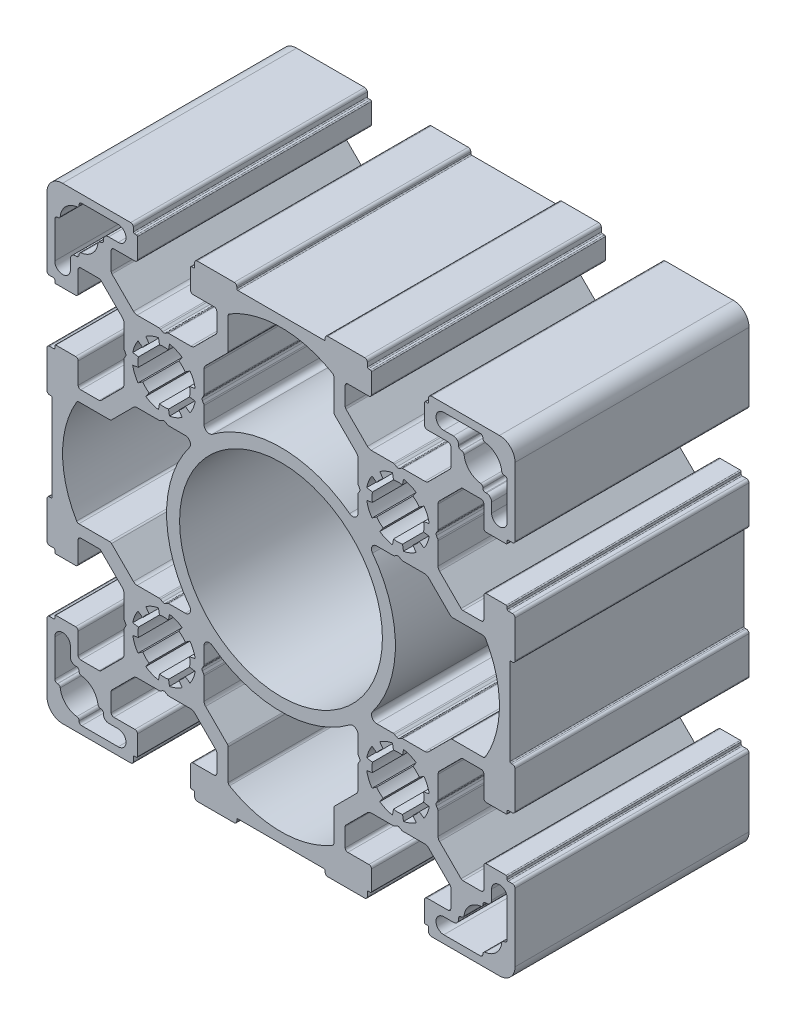
from build123d import *

# Parameters (mm, degrees)
SKETCH_1_R      = 19.5
EXTRUDE_1_DEPTH = 45


with BuildPart() as part:
    # Эскиз1 → Бобышка-Вытянуть1 (new body)
    with BuildSketch(Plane.XY):
        with BuildLine():
            Line((-35.141853673, 36.152210307), (-35.141853673, 40.388068593))
            ThreePointArc((-35.141853673, 40.388068593), (-35.21797414, 40.770752026), (-35.434746892, 41.095175374))
            Line((-35.434746892, 41.095175374), (-37.681504654, 43.341933137))
            Line((-37.681504654, 43.341933137), (-39.566246974, 45.226675456))
            ThreePointArc((-39.566246974, 45.226675456), (-39.728458648, 45.335061832), (-39.919800364, 45.373122066))
            Line((-39.919800364, 45.373122066), (-43.441373239, 45.373122066))
            ThreePointArc((-43.441373239, 45.373122066), (-43.79492663, 45.226675456), (-43.941373239, 44.873122066))
            Line((-43.941373239, 44.873122066), (-43.941373239, 40.823122066))
            ThreePointArc((-43.941373239, 40.823122066), (-44.087819849, 40.469568675), (-44.441373239, 40.323122066))
            Line((-44.441373239, 40.323122066), (-48.241373239, 40.323122066))
            ThreePointArc((-48.241373239, 40.323122066), (-48.382794596, 40.381700709), (-48.441373239, 40.523122066))
            Line((-48.441373239, 40.523122066), (-48.441373239, 40.923122066))
            ThreePointArc((-48.441373239, 40.923122066), (-48.499951883, 41.064543422), (-48.641373239, 41.123122066))
            Line((-48.641373239, 41.123122066), (-49.441373239, 41.123122066))
            ThreePointArc((-49.441373239, 41.123122066), (-49.79492663, 41.269568675), (-49.941373239, 41.623122066))
            Line((-49.941373239, 41.623122066), (-49.941373239, 54.723122066))
            ThreePointArc((-49.941373239, 54.723122066), (-49.062693583, 56.844442409), (-46.941373239, 57.723122066))
            Line((-46.941373239, 57.723122066), (-33.841373239, 57.723122066))
            ThreePointArc((-33.841373239, 57.723122066), (-33.487819849, 57.576675456), (-33.341373239, 57.223122066))
            Line((-33.341373239, 57.223122066), (-33.341373239, 56.423122066))
            ThreePointArc((-33.341373239, 56.423122066), (-33.282794596, 56.281700709), (-33.141373239, 56.223122066))
            Line((-33.141373239, 56.223122066), (-32.741373239, 56.223122066))
            ThreePointArc((-32.741373239, 56.223122066), (-32.599951883, 56.164543422), (-32.541373239, 56.023122066))
            Line((-32.541373239, 56.023122066), (-32.541373239, 52.223122066))
            ThreePointArc((-32.541373239, 52.223122066), (-32.687819849, 51.869568675), (-33.041373239, 51.723122066))
            Line((-33.041373239, 51.723122066), (-37.091373239, 51.723122066))
            ThreePointArc((-37.091373239, 51.723122066), (-37.44492663, 51.576675456), (-37.591373239, 51.223122066))
            Line((-37.591373239, 51.223122066), (-37.591373239, 47.70154919))
            ThreePointArc((-37.591373239, 47.70154919), (-37.553313006, 47.510207474), (-37.44492663, 47.3479958))
            Line((-37.44492663, 47.3479958), (-35.560184311, 45.463253481))
            Line((-35.560184311, 45.463253481), (-33.313426548, 43.216495718))
            ThreePointArc((-33.313426548, 43.216495718), (-32.989003199, 42.999722967), (-32.606319767, 42.923602499))
            Line((-32.606319767, 42.923602499), (-28.370461481, 42.923602499))
            ThreePointArc((-28.370461481, 42.923602499), (-28.241051958, 42.906565412), (-28.120461481, 42.856615201))
            Line((-28.120461481, 42.856615201), (-27.691373239, 42.608880989))
            ThreePointArc((-27.691373239, 42.608880989), (-27.441373239, 42.541893691), (-27.191373239, 42.608880989))
            Line((-27.191373239, 42.608880989), (-26.762284998, 42.856615201))
            ThreePointArc((-26.762284998, 42.856615201), (-26.64169452, 42.906565412), (-26.512284998, 42.923602499))
            Line((-26.512284998, 42.923602499), (-22.276426712, 42.923602499))
            ThreePointArc((-22.276426712, 42.923602499), (-21.89374328, 42.999722967), (-21.569319931, 43.216495718))
            Line((-21.569319931, 43.216495718), (-19.322562168, 45.463253481))
            Line((-19.322562168, 45.463253481), (-17.437819849, 47.3479958))
            ThreePointArc((-17.437819849, 47.3479958), (-17.329433473, 47.510207474), (-17.291373239, 47.70154919))
            Line((-17.291373239, 47.70154919), (-17.291373239, 51.223122066))
            ThreePointArc((-17.291373239, 51.223122066), (-17.437819849, 51.576675456), (-17.791373239, 51.723122066))
            Line((-17.791373239, 51.723122066), (-21.841373239, 51.723122066))
            ThreePointArc((-21.841373239, 51.723122066), (-22.19492663, 51.869568675), (-22.341373239, 52.223122066))
            Line((-22.341373239, 52.223122066), (-22.341373239, 56.023122066))
            ThreePointArc((-22.341373239, 56.023122066), (-22.282794596, 56.164543422), (-22.141373239, 56.223122066))
            Line((-22.141373239, 56.223122066), (-21.741373239, 56.223122066))
            ThreePointArc((-21.741373239, 56.223122066), (-21.599951883, 56.281700709), (-21.541373239, 56.423122066))
            Line((-21.541373239, 56.423122066), (-21.541373239, 57.223122066))
            ThreePointArc((-21.541373239, 57.223122066), (-21.39492663, 57.576675456), (-21.041373239, 57.723122066))
            Line((-21.041373239, 57.723122066), (-13.941373239, 57.723122066))
            ThreePointArc((-13.941373239, 57.723122066), (-13.587819849, 57.576675456), (-13.441373239, 57.223122066))
            Line((-13.441373239, 57.223122066), (-13.441373239, 56.923122066))
            ThreePointArc((-13.441373239, 56.923122066), (-13.382794596, 56.781700709), (-13.241373239, 56.723122066))
            Line((-13.241373239, 56.723122066), (3.358626761, 56.723122066))
            ThreePointArc((3.358626761, 56.723122066), (3.500048117, 56.781700709), (3.558626761, 56.923122066))
            Line((3.558626761, 56.923122066), (3.558626761, 57.223122066))
            ThreePointArc((3.558626761, 57.223122066), (3.70507337, 57.576675456), (4.058626761, 57.723122066))
            Line((4.058626761, 57.723122066), (11.158626761, 57.723122066))
            ThreePointArc((11.158626761, 57.723122066), (11.512180151, 57.576675456), (11.658626761, 57.223122066))
            Line((11.658626761, 57.223122066), (11.658626761, 56.423122066))
            ThreePointArc((11.658626761, 56.423122066), (11.717205404, 56.281700709), (11.858626761, 56.223122066))
            Line((11.858626761, 56.223122066), (12.258626761, 56.223122066))
            ThreePointArc((12.258626761, 56.223122066), (12.400048117, 56.164543422), (12.458626761, 56.023122066))
            Line((12.458626761, 56.023122066), (12.458626761, 52.223122066))
            ThreePointArc((12.458626761, 52.223122066), (12.312180151, 51.869568675), (11.958626761, 51.723122066))
            Line((11.958626761, 51.723122066), (7.908626761, 51.723122066))
            ThreePointArc((7.908626761, 51.723122066), (7.55507337, 51.576675456), (7.408626761, 51.223122066))
            Line((7.408626761, 51.223122066), (7.408626761, 47.70154919))
            ThreePointArc((7.408626761, 47.70154919), (7.446686994, 47.510207474), (7.55507337, 47.3479958))
            Line((7.55507337, 47.3479958), (9.439815689, 45.463253481))
            Line((9.439815689, 45.463253481), (11.686573452, 43.216495718))
            ThreePointArc((11.686573452, 43.216495718), (12.010996801, 42.999722967), (12.393680233, 42.923602499))
            Line((12.393680233, 42.923602499), (16.629538519, 42.923602499))
            ThreePointArc((16.629538519, 42.923602499), (16.758948042, 42.906565412), (16.879538519, 42.856615201))
            Line((16.879538519, 42.856615201), (17.308626761, 42.608880989))
            ThreePointArc((17.308626761, 42.608880989), (17.558626761, 42.541893691), (17.808626761, 42.608880989))
            Line((17.808626761, 42.608880989), (18.237715002, 42.856615201))
            ThreePointArc((18.237715002, 42.856615201), (18.35830548, 42.906565412), (18.487715002, 42.923602499))
            Line((18.487715002, 42.923602499), (22.723573288, 42.923602499))
            ThreePointArc((22.723573288, 42.923602499), (23.10625672, 42.999722967), (23.430680069, 43.216495718))
            Line((23.430680069, 43.216495718), (25.677437832, 45.463253481))
            Line((25.677437832, 45.463253481), (27.562180151, 47.3479958))
            ThreePointArc((27.562180151, 47.3479958), (27.670566527, 47.510207474), (27.708626761, 47.70154919))
            Line((27.708626761, 47.70154919), (27.708626761, 51.223122066))
            ThreePointArc((27.708626761, 51.223122066), (27.562180151, 51.576675456), (27.208626761, 51.723122066))
            Line((27.208626761, 51.723122066), (23.158626761, 51.723122066))
            ThreePointArc((23.158626761, 51.723122066), (22.80507337, 51.869568675), (22.658626761, 52.223122066))
            Line((22.658626761, 52.223122066), (22.658626761, 56.023122066))
            ThreePointArc((22.658626761, 56.023122066), (22.717205404, 56.164543422), (22.858626761, 56.223122066))
            Line((22.858626761, 56.223122066), (23.258626761, 56.223122066))
            ThreePointArc((23.258626761, 56.223122066), (23.400048117, 56.281700709), (23.458626761, 56.423122066))
            Line((23.458626761, 56.423122066), (23.458626761, 57.223122066))
            ThreePointArc((23.458626761, 57.223122066), (23.60507337, 57.576675456), (23.958626761, 57.723122066))
            Line((23.958626761, 57.723122066), (37.058626761, 57.723122066))
            ThreePointArc((37.058626761, 57.723122066), (39.179947104, 56.844442409), (40.058626761, 54.723122066))
            Line((40.058626761, 54.723122066), (40.058626761, 41.623122066))
            ThreePointArc((40.058626761, 41.623122066), (39.912180151, 41.269568675), (39.558626761, 41.123122066))
            Line((39.558626761, 41.123122066), (38.758626761, 41.123122066))
            ThreePointArc((38.758626761, 41.123122066), (38.617205404, 41.064543422), (38.558626761, 40.923122066))
            Line((38.558626761, 40.923122066), (38.558626761, 40.523122066))
            ThreePointArc((38.558626761, 40.523122066), (38.500048117, 40.381700709), (38.358626761, 40.323122066))
            Line((38.358626761, 40.323122066), (34.558626761, 40.323122066))
            ThreePointArc((34.558626761, 40.323122066), (34.20507337, 40.469568675), (34.058626761, 40.823122066))
            Line((34.058626761, 40.823122066), (34.058626761, 44.873122066))
            ThreePointArc((34.058626761, 44.873122066), (33.912180151, 45.226675456), (33.558626761, 45.373122066))
            Line((33.558626761, 45.373122066), (30.037053885, 45.373122066))
            ThreePointArc((30.037053885, 45.373122066), (29.845712169, 45.335061832), (29.683500495, 45.226675456))
            Line((29.683500495, 45.226675456), (27.798758175, 43.341933137))
            Line((27.798758175, 43.341933137), (25.552000413, 41.095175374))
            ThreePointArc((25.552000413, 41.095175374), (25.335227661, 40.770752026), (25.259107194, 40.388068593))
            Line((25.259107194, 40.388068593), (25.259107194, 36.152210307))
            ThreePointArc((25.259107194, 36.152210307), (25.242070107, 36.022800785), (25.192119896, 35.902210307))
            Line((25.192119896, 35.902210307), (24.944385684, 35.473122066))
            ThreePointArc((24.944385684, 35.473122066), (24.877398386, 35.223122066), (24.944385684, 34.973122066))
            Line((24.944385684, 34.973122066), (25.192119896, 34.544033824))
            ThreePointArc((25.192119896, 34.544033824), (25.242070107, 34.423443347), (25.259107194, 34.294033824))
            Line((25.259107194, 34.294033824), (25.259107194, 30.058175538))
            ThreePointArc((25.259107194, 30.058175538), (25.335227661, 29.675492106), (25.552000413, 29.351068757))
            Line((25.552000413, 29.351068757), (27.798758175, 27.104310994))
            Line((27.798758175, 27.104310994), (29.683500495, 25.219568675))
            ThreePointArc((29.683500495, 25.219568675), (29.845712169, 25.111182299), (30.037053885, 25.073122066))
            Line((30.037053885, 25.073122066), (33.558626761, 25.073122066))
            ThreePointArc((33.558626761, 25.073122066), (33.912180151, 25.219568675), (34.058626761, 25.573122066))
            Line((34.058626761, 25.573122066), (34.058626761, 29.623122066))
            ThreePointArc((34.058626761, 29.623122066), (34.20507337, 29.976675456), (34.558626761, 30.123122066))
            Line((34.558626761, 30.123122066), (38.358626761, 30.123122066))
            ThreePointArc((38.358626761, 30.123122066), (38.500048117, 30.064543422), (38.558626761, 29.923122066))
            Line((38.558626761, 29.923122066), (38.558626761, 29.523122066))
            ThreePointArc((38.558626761, 29.523122066), (38.617205404, 29.381700709), (38.758626761, 29.323122066))
            Line((38.758626761, 29.323122066), (39.558626761, 29.323122066))
            ThreePointArc((39.558626761, 29.323122066), (39.912180151, 29.176675456), (40.058626761, 28.823122066))
            Line((40.058626761, 28.823122066), (40.058626761, 21.723122066))
            ThreePointArc((40.058626761, 21.723122066), (39.912180151, 21.369568675), (39.558626761, 21.223122066))
            Line((39.558626761, 21.223122066), (39.258626761, 21.223122066))
            ThreePointArc((39.258626761, 21.223122066), (39.117205404, 21.164543422), (39.058626761, 21.023122066))
            Line((39.058626761, 21.023122066), (39.058626761, 4.423122066))
            ThreePointArc((39.058626761, 4.423122066), (39.117205404, 4.281700709), (39.258626761, 4.223122066))
            Line((39.258626761, 4.223122066), (39.558626761, 4.223122066))
            ThreePointArc((39.558626761, 4.223122066), (39.912180151, 4.076675456), (40.058626761, 3.723122066))
            Line((40.058626761, 3.723122066), (40.058626761, -3.376877934))
            ThreePointArc((40.058626761, -3.376877934), (39.912180151, -3.730431325), (39.558626761, -3.876877934))
            Line((39.558626761, -3.876877934), (38.758626761, -3.876877934))
            ThreePointArc((38.758626761, -3.876877934), (38.617205404, -3.935456578), (38.558626761, -4.076877934))
            Line((38.558626761, -4.076877934), (38.558626761, -4.476877934))
            ThreePointArc((38.558626761, -4.476877934), (38.500048117, -4.618299291), (38.358626761, -4.676877934))
            Line((38.358626761, -4.676877934), (34.558626761, -4.676877934))
            ThreePointArc((34.558626761, -4.676877934), (34.20507337, -4.530431325), (34.058626761, -4.176877934))
            Line((34.058626761, -4.176877934), (34.058626761, -0.126877934))
            ThreePointArc((34.058626761, -0.126877934), (33.912180151, 0.226675456), (33.558626761, 0.373122066))
            Line((33.558626761, 0.373122066), (30.037053885, 0.373122066))
            ThreePointArc((30.037053885, 0.373122066), (29.845712169, 0.335061832), (29.683500495, 0.226675456))
            Line((29.683500495, 0.226675456), (27.798758175, -1.658066863))
            Line((27.798758175, -1.658066863), (25.552000413, -3.904824626))
            ThreePointArc((25.552000413, -3.904824626), (25.335227661, -4.229247974), (25.259107194, -4.611931407))
            Line((25.259107194, -4.611931407), (25.259107194, -8.847789693))
            ThreePointArc((25.259107194, -8.847789693), (25.242070107, -8.977199215), (25.192119896, -9.097789693))
            Line((25.192119896, -9.097789693), (24.944385684, -9.526877934))
            ThreePointArc((24.944385684, -9.526877934), (24.877398386, -9.776877934), (24.944385684, -10.026877934))
            Line((24.944385684, -10.026877934), (25.192119896, -10.455966176))
            ThreePointArc((25.192119896, -10.455966176), (25.242070107, -10.576556653), (25.259107194, -10.705966176))
            Line((25.259107194, -10.705966176), (25.259107194, -14.941824462))
            ThreePointArc((25.259107194, -14.941824462), (25.335227661, -15.324507894), (25.552000413, -15.648931243))
            Line((25.552000413, -15.648931243), (27.798758175, -17.895689006))
            Line((27.798758175, -17.895689006), (29.683500495, -19.780431325))
            ThreePointArc((29.683500495, -19.780431325), (29.845712169, -19.888817701), (30.037053885, -19.926877934))
            Line((30.037053885, -19.926877934), (33.558626761, -19.926877934))
            ThreePointArc((33.558626761, -19.926877934), (33.912180151, -19.780431325), (34.058626761, -19.426877934))
            Line((34.058626761, -19.426877934), (34.058626761, -15.376877934))
            ThreePointArc((34.058626761, -15.376877934), (34.20507337, -15.023324544), (34.558626761, -14.876877934))
            Line((34.558626761, -14.876877934), (38.358626761, -14.876877934))
            ThreePointArc((38.358626761, -14.876877934), (38.500048117, -14.935456578), (38.558626761, -15.076877934))
            Line((38.558626761, -15.076877934), (38.558626761, -15.476877934))
            ThreePointArc((38.558626761, -15.476877934), (38.617205404, -15.618299291), (38.758626761, -15.676877934))
            Line((38.758626761, -15.676877934), (39.558626761, -15.676877934))
            ThreePointArc((39.558626761, -15.676877934), (39.912180151, -15.823324544), (40.058626761, -16.176877934))
            Line((40.058626761, -16.176877934), (40.058626761, -29.276877934))
            ThreePointArc((40.058626761, -29.276877934), (39.179947104, -31.398198278), (37.058626761, -32.276877934))
            Line((37.058626761, -32.276877934), (23.958626761, -32.276877934))
            ThreePointArc((23.958626761, -32.276877934), (23.60507337, -32.130431325), (23.458626761, -31.776877934))
            Line((23.458626761, -31.776877934), (23.458626761, -30.976877934))
            ThreePointArc((23.458626761, -30.976877934), (23.400048117, -30.835456578), (23.258626761, -30.776877934))
            Line((23.258626761, -30.776877934), (22.858626761, -30.776877934))
            ThreePointArc((22.858626761, -30.776877934), (22.717205404, -30.718299291), (22.658626761, -30.576877934))
            Line((22.658626761, -30.576877934), (22.658626761, -26.776877934))
            ThreePointArc((22.658626761, -26.776877934), (22.80507337, -26.423324544), (23.158626761, -26.276877934))
            Line((23.158626761, -26.276877934), (27.208626761, -26.276877934))
            ThreePointArc((27.208626761, -26.276877934), (27.562180151, -26.130431325), (27.708626761, -25.776877934))
            Line((27.708626761, -25.776877934), (27.708626761, -22.255305059))
            ThreePointArc((27.708626761, -22.255305059), (27.670566527, -22.063963343), (27.562180151, -21.901751668))
            Line((27.562180151, -21.901751668), (25.677437832, -20.017009349))
            Line((25.677437832, -20.017009349), (23.430680069, -17.770251587))
            ThreePointArc((23.430680069, -17.770251587), (23.10625672, -17.553478835), (22.723573288, -17.477358368))
            Line((22.723573288, -17.477358368), (18.487715002, -17.477358368))
            ThreePointArc((18.487715002, -17.477358368), (18.35830548, -17.460321281), (18.237715002, -17.41037107))
            Line((18.237715002, -17.41037107), (17.808626761, -17.162636858))
            ThreePointArc((17.808626761, -17.162636858), (17.558626761, -17.09564956), (17.308626761, -17.162636858))
            Line((17.308626761, -17.162636858), (16.879538519, -17.41037107))
            ThreePointArc((16.879538519, -17.41037107), (16.758948042, -17.460321281), (16.629538519, -17.477358368))
            Line((16.629538519, -17.477358368), (12.393680233, -17.477358368))
            ThreePointArc((12.393680233, -17.477358368), (12.010996801, -17.553478835), (11.686573452, -17.770251587))
            Line((11.686573452, -17.770251587), (9.439815689, -20.017009349))
            Line((9.439815689, -20.017009349), (7.55507337, -21.901751668))
            ThreePointArc((7.55507337, -21.901751668), (7.446686994, -22.063963343), (7.408626761, -22.255305059))
            Line((7.408626761, -22.255305059), (7.408626761, -25.776877934))
            ThreePointArc((7.408626761, -25.776877934), (7.55507337, -26.130431325), (7.908626761, -26.276877934))
            Line((7.908626761, -26.276877934), (11.958626761, -26.276877934))
            ThreePointArc((11.958626761, -26.276877934), (12.312180151, -26.423324544), (12.458626761, -26.776877934))
            Line((12.458626761, -26.776877934), (12.458626761, -30.576877934))
            ThreePointArc((12.458626761, -30.576877934), (12.400048117, -30.718299291), (12.258626761, -30.776877934))
            Line((12.258626761, -30.776877934), (11.858626761, -30.776877934))
            ThreePointArc((11.858626761, -30.776877934), (11.717205404, -30.835456578), (11.658626761, -30.976877934))
            Line((11.658626761, -30.976877934), (11.658626761, -31.776877934))
            ThreePointArc((11.658626761, -31.776877934), (11.512180151, -32.130431325), (11.158626761, -32.276877934))
            Line((11.158626761, -32.276877934), (4.058626761, -32.276877934))
            ThreePointArc((4.058626761, -32.276877934), (3.70507337, -32.130431325), (3.558626761, -31.776877934))
            Line((3.558626761, -31.776877934), (3.558626761, -31.476877934))
            ThreePointArc((3.558626761, -31.476877934), (3.500048117, -31.335456578), (3.358626761, -31.276877934))
            Line((3.358626761, -31.276877934), (-13.241373239, -31.276877934))
            ThreePointArc((-13.241373239, -31.276877934), (-13.382794596, -31.335456578), (-13.441373239, -31.476877934))
            Line((-13.441373239, -31.476877934), (-13.441373239, -31.776877934))
            ThreePointArc((-13.441373239, -31.776877934), (-13.587819849, -32.130431325), (-13.941373239, -32.276877934))
            Line((-13.941373239, -32.276877934), (-21.041373239, -32.276877934))
            ThreePointArc((-21.041373239, -32.276877934), (-21.39492663, -32.130431325), (-21.541373239, -31.776877934))
            Line((-21.541373239, -31.776877934), (-21.541373239, -30.976877934))
            ThreePointArc((-21.541373239, -30.976877934), (-21.599951883, -30.835456578), (-21.741373239, -30.776877934))
            Line((-21.741373239, -30.776877934), (-22.141373239, -30.776877934))
            ThreePointArc((-22.141373239, -30.776877934), (-22.282794596, -30.718299291), (-22.341373239, -30.576877934))
            Line((-22.341373239, -30.576877934), (-22.341373239, -26.776877934))
            ThreePointArc((-22.341373239, -26.776877934), (-22.19492663, -26.423324544), (-21.841373239, -26.276877934))
            Line((-21.841373239, -26.276877934), (-17.791373239, -26.276877934))
            ThreePointArc((-17.791373239, -26.276877934), (-17.437819849, -26.130431325), (-17.291373239, -25.776877934))
            Line((-17.291373239, -25.776877934), (-17.291373239, -22.255305059))
            ThreePointArc((-17.291373239, -22.255305059), (-17.329433473, -22.063963343), (-17.437819849, -21.901751668))
            Line((-17.437819849, -21.901751668), (-19.322562168, -20.017009349))
            Line((-19.322562168, -20.017009349), (-21.569319931, -17.770251587))
            ThreePointArc((-21.569319931, -17.770251587), (-21.89374328, -17.553478835), (-22.276426712, -17.477358368))
            Line((-22.276426712, -17.477358368), (-26.512284998, -17.477358368))
            ThreePointArc((-26.512284998, -17.477358368), (-26.64169452, -17.460321281), (-26.762284998, -17.41037107))
            Line((-26.762284998, -17.41037107), (-27.191373239, -17.162636858))
            ThreePointArc((-27.191373239, -17.162636858), (-27.441373239, -17.09564956), (-27.691373239, -17.162636858))
            Line((-27.691373239, -17.162636858), (-28.120461481, -17.41037107))
            ThreePointArc((-28.120461481, -17.41037107), (-28.241051958, -17.460321281), (-28.370461481, -17.477358368))
            Line((-28.370461481, -17.477358368), (-32.606319767, -17.477358368))
            ThreePointArc((-32.606319767, -17.477358368), (-32.989003199, -17.553478835), (-33.313426548, -17.770251587))
            Line((-33.313426548, -17.770251587), (-35.560184311, -20.017009349))
            Line((-35.560184311, -20.017009349), (-37.44492663, -21.901751668))
            ThreePointArc((-37.44492663, -21.901751668), (-37.553313006, -22.063963343), (-37.591373239, -22.255305059))
            Line((-37.591373239, -22.255305059), (-37.591373239, -25.776877934))
            ThreePointArc((-37.591373239, -25.776877934), (-37.44492663, -26.130431325), (-37.091373239, -26.276877934))
            Line((-37.091373239, -26.276877934), (-33.041373239, -26.276877934))
            ThreePointArc((-33.041373239, -26.276877934), (-32.687819849, -26.423324544), (-32.541373239, -26.776877934))
            Line((-32.541373239, -26.776877934), (-32.541373239, -30.576877934))
            ThreePointArc((-32.541373239, -30.576877934), (-32.599951883, -30.718299291), (-32.741373239, -30.776877934))
            Line((-32.741373239, -30.776877934), (-33.141373239, -30.776877934))
            ThreePointArc((-33.141373239, -30.776877934), (-33.282794596, -30.835456578), (-33.341373239, -30.976877934))
            Line((-33.341373239, -30.976877934), (-33.341373239, -31.776877934))
            ThreePointArc((-33.341373239, -31.776877934), (-33.487819849, -32.130431325), (-33.841373239, -32.276877934))
            Line((-33.841373239, -32.276877934), (-46.941373239, -32.276877934))
            ThreePointArc((-46.941373239, -32.276877934), (-49.062693583, -31.398198278), (-49.941373239, -29.276877934))
            Line((-49.941373239, -29.276877934), (-49.941373239, -16.176877934))
            ThreePointArc((-49.941373239, -16.176877934), (-49.79492663, -15.823324544), (-49.441373239, -15.676877934))
            Line((-49.441373239, -15.676877934), (-48.641373239, -15.676877934))
            ThreePointArc((-48.641373239, -15.676877934), (-48.499951883, -15.618299291), (-48.441373239, -15.476877934))
            Line((-48.441373239, -15.476877934), (-48.441373239, -15.076877934))
            ThreePointArc((-48.441373239, -15.076877934), (-48.382794596, -14.935456578), (-48.241373239, -14.876877934))
            Line((-48.241373239, -14.876877934), (-44.441373239, -14.876877934))
            ThreePointArc((-44.441373239, -14.876877934), (-44.087819849, -15.023324544), (-43.941373239, -15.376877934))
            Line((-43.941373239, -15.376877934), (-43.941373239, -19.426877934))
            ThreePointArc((-43.941373239, -19.426877934), (-43.79492663, -19.780431325), (-43.441373239, -19.926877934))
            Line((-43.441373239, -19.926877934), (-39.919800364, -19.926877934))
            ThreePointArc((-39.919800364, -19.926877934), (-39.728458648, -19.888817701), (-39.566246974, -19.780431325))
            Line((-39.566246974, -19.780431325), (-37.681504654, -17.895689006))
            Line((-37.681504654, -17.895689006), (-35.434746892, -15.648931243))
            ThreePointArc((-35.434746892, -15.648931243), (-35.21797414, -15.324507894), (-35.141853673, -14.941824462))
            Line((-35.141853673, -14.941824462), (-35.141853673, -10.705966176))
            ThreePointArc((-35.141853673, -10.705966176), (-35.124816586, -10.576556653), (-35.074866375, -10.455966176))
            Line((-35.074866375, -10.455966176), (-34.827132163, -10.026877934))
            ThreePointArc((-34.827132163, -10.026877934), (-34.760144865, -9.776877934), (-34.827132163, -9.526877934))
            Line((-34.827132163, -9.526877934), (-35.074866375, -9.097789693))
            ThreePointArc((-35.074866375, -9.097789693), (-35.124816586, -8.977199215), (-35.141853673, -8.847789693))
            Line((-35.141853673, -8.847789693), (-35.141853673, -4.611931407))
            ThreePointArc((-35.141853673, -4.611931407), (-35.21797414, -4.229247974), (-35.434746892, -3.904824626))
            Line((-35.434746892, -3.904824626), (-37.681504654, -1.658066863))
            Line((-37.681504654, -1.658066863), (-39.566246974, 0.226675456))
            ThreePointArc((-39.566246974, 0.226675456), (-39.728458648, 0.335061832), (-39.919800364, 0.373122066))
            Line((-39.919800364, 0.373122066), (-43.441373239, 0.373122066))
            ThreePointArc((-43.441373239, 0.373122066), (-43.79492663, 0.226675456), (-43.941373239, -0.126877934))
            Line((-43.941373239, -0.126877934), (-43.941373239, -4.176877934))
            ThreePointArc((-43.941373239, -4.176877934), (-44.087819849, -4.530431325), (-44.441373239, -4.676877934))
            Line((-44.441373239, -4.676877934), (-48.241373239, -4.676877934))
            ThreePointArc((-48.241373239, -4.676877934), (-48.382794596, -4.618299291), (-48.441373239, -4.476877934))
            Line((-48.441373239, -4.476877934), (-48.441373239, -4.076877934))
            ThreePointArc((-48.441373239, -4.076877934), (-48.499951883, -3.935456578), (-48.641373239, -3.876877934))
            Line((-48.641373239, -3.876877934), (-49.441373239, -3.876877934))
            ThreePointArc((-49.441373239, -3.876877934), (-49.79492663, -3.730431325), (-49.941373239, -3.376877934))
            Line((-49.941373239, -3.376877934), (-49.941373239, 3.723122066))
            ThreePointArc((-49.941373239, 3.723122066), (-49.79492663, 4.076675456), (-49.441373239, 4.223122066))
            Line((-49.441373239, 4.223122066), (-49.141373239, 4.223122066))
            ThreePointArc((-49.141373239, 4.223122066), (-48.999951883, 4.281700709), (-48.941373239, 4.423122066))
            Line((-48.941373239, 4.423122066), (-48.941373239, 21.023122066))
            ThreePointArc((-48.941373239, 21.023122066), (-48.999951883, 21.164543422), (-49.141373239, 21.223122066))
            Line((-49.141373239, 21.223122066), (-49.441373239, 21.223122066))
            ThreePointArc((-49.441373239, 21.223122066), (-49.79492663, 21.369568675), (-49.941373239, 21.723122066))
            Line((-49.941373239, 21.723122066), (-49.941373239, 28.823122066))
            ThreePointArc((-49.941373239, 28.823122066), (-49.79492663, 29.176675456), (-49.441373239, 29.323122066))
            Line((-49.441373239, 29.323122066), (-48.641373239, 29.323122066))
            ThreePointArc((-48.641373239, 29.323122066), (-48.499951883, 29.381700709), (-48.441373239, 29.523122066))
            Line((-48.441373239, 29.523122066), (-48.441373239, 29.923122066))
            ThreePointArc((-48.441373239, 29.923122066), (-48.382794596, 30.064543422), (-48.241373239, 30.123122066))
            Line((-48.241373239, 30.123122066), (-44.441373239, 30.123122066))
            ThreePointArc((-44.441373239, 30.123122066), (-44.087819849, 29.976675456), (-43.941373239, 29.623122066))
            Line((-43.941373239, 29.623122066), (-43.941373239, 25.573122066))
            ThreePointArc((-43.941373239, 25.573122066), (-43.79492663, 25.219568675), (-43.441373239, 25.073122066))
            Line((-43.441373239, 25.073122066), (-39.919800364, 25.073122066))
            ThreePointArc((-39.919800364, 25.073122066), (-39.728458648, 25.111182299), (-39.566246974, 25.219568675))
            Line((-39.566246974, 25.219568675), (-37.681504654, 27.104310994))
            Line((-37.681504654, 27.104310994), (-35.434746892, 29.351068757))
            ThreePointArc((-35.434746892, 29.351068757), (-35.21797414, 29.675492106), (-35.141853673, 30.058175538))
            Line((-35.141853673, 30.058175538), (-35.141853673, 34.294033824))
            ThreePointArc((-35.141853673, 34.294033824), (-35.124816586, 34.423443347), (-35.074866375, 34.544033824))
            Line((-35.074866375, 34.544033824), (-34.827132163, 34.973122066))
            ThreePointArc((-34.827132163, 34.973122066), (-34.760144865, 35.223122066), (-34.827132163, 35.473122066))
            Line((-34.827132163, 35.473122066), (-35.074866375, 35.902210307))
            ThreePointArc((-35.074866375, 35.902210307), (-35.124816586, 36.022800785), (-35.141853673, 36.152210307))
        make_face()
        with Locations((-4.941373239, 12.723122066)):
            Circle(SKETCH_1_R, mode=Mode.SUBTRACT)
        with BuildLine():
            Line((-48.441373239, 51.048122066), (-48.441373239, 44.031073139))
            ThreePointArc((-48.441373239, 44.031073139), (-46.941373239, 42.531073139), (-45.441373239, 44.031073139))
            Line((-45.441373239, 44.031073139), (-45.441373239, 45.873122066))
            ThreePointArc((-45.441373239, 45.873122066), (-45.148480021, 46.580228847), (-44.441373239, 46.873122066))
            Line((-44.441373239, 46.873122066), (-44.266373239, 46.873122066))
            ThreePointArc((-44.266373239, 46.873122066), (-43.912819849, 47.019568675), (-43.766373239, 47.373122066))
            Line((-43.766373239, 47.373122066), (-43.766373239, 47.428352655))
            ThreePointArc((-43.766373239, 47.428352655), (-43.64061947, 47.759924305), (-43.326614203, 47.924710415))
            ThreePointArc((-43.326614203, 47.924710415), (-41.185433488, 48.967182314), (-40.142961589, 51.10836303))
            ThreePointArc((-40.142961589, 51.10836303), (-39.978175478, 51.422368296), (-39.646603828, 51.548122066))
            Line((-39.646603828, 51.548122066), (-39.591373239, 51.548122066))
            ThreePointArc((-39.591373239, 51.548122066), (-39.237819849, 51.694568675), (-39.091373239, 52.048122066))
            Line((-39.091373239, 52.048122066), (-39.091373239, 52.223122066))
            ThreePointArc((-39.091373239, 52.223122066), (-38.798480021, 52.930228847), (-38.091373239, 53.223122066))
            Line((-38.091373239, 53.223122066), (-36.249324313, 53.223122066))
            ThreePointArc((-36.249324313, 53.223122066), (-34.749324313, 54.723122066), (-36.249324313, 56.223122066))
            Line((-36.249324313, 56.223122066), (-43.266373239, 56.223122066))
            ThreePointArc((-43.266373239, 56.223122066), (-43.61992663, 56.076675456), (-43.766373239, 55.723122066))
            Line((-43.766373239, 55.723122066), (-43.766373239, 55.667891477))
            ThreePointArc((-43.766373239, 55.667891477), (-43.892127009, 55.336319827), (-44.206132276, 55.171533716))
            ThreePointArc((-44.206132276, 55.171533716), (-46.347312991, 54.129061817), (-47.38978489, 51.987881102))
            ThreePointArc((-47.38978489, 51.987881102), (-47.554571001, 51.673875835), (-47.88614265, 51.548122066))
            Line((-47.88614265, 51.548122066), (-47.941373239, 51.548122066))
            ThreePointArc((-47.941373239, 51.548122066), (-48.29492663, 51.401675456), (-48.441373239, 51.048122066))
        make_face(mode=Mode.SUBTRACT)
        with BuildLine():
            Line((33.383626761, 56.223122066), (26.366577834, 56.223122066))
            ThreePointArc((26.366577834, 56.223122066), (24.866577834, 54.723122066), (26.366577834, 53.223122066))
            Line((26.366577834, 53.223122066), (28.208626761, 53.223122066))
            ThreePointArc((28.208626761, 53.223122066), (28.915733542, 52.930228847), (29.208626761, 52.223122066))
            Line((29.208626761, 52.223122066), (29.208626761, 52.048122066))
            ThreePointArc((29.208626761, 52.048122066), (29.35507337, 51.694568675), (29.708626761, 51.548122066))
            Line((29.708626761, 51.548122066), (29.76385735, 51.548122066))
            ThreePointArc((29.76385735, 51.548122066), (30.095428999, 51.422368296), (30.26021511, 51.10836303))
            ThreePointArc((30.26021511, 51.10836303), (31.302687009, 48.967182314), (33.443867724, 47.924710415))
            ThreePointArc((33.443867724, 47.924710415), (33.757872991, 47.759924305), (33.883626761, 47.428352655))
            Line((33.883626761, 47.428352655), (33.883626761, 47.373122066))
            ThreePointArc((33.883626761, 47.373122066), (34.03007337, 47.019568675), (34.383626761, 46.873122066))
            Line((34.383626761, 46.873122066), (34.558626761, 46.873122066))
            ThreePointArc((34.558626761, 46.873122066), (35.265733542, 46.580228847), (35.558626761, 45.873122066))
            Line((35.558626761, 45.873122066), (35.558626761, 44.031073139))
            ThreePointArc((35.558626761, 44.031073139), (37.058626761, 42.531073139), (38.558626761, 44.031073139))
            Line((38.558626761, 44.031073139), (38.558626761, 51.048122066))
            ThreePointArc((38.558626761, 51.048122066), (38.412180151, 51.401675456), (38.058626761, 51.548122066))
            Line((38.058626761, 51.548122066), (38.003396172, 51.548122066))
            ThreePointArc((38.003396172, 51.548122066), (37.671824522, 51.673875835), (37.507038411, 51.987881102))
            ThreePointArc((37.507038411, 51.987881102), (36.464566512, 54.129061817), (34.323385797, 55.171533716))
            ThreePointArc((34.323385797, 55.171533716), (34.00938053, 55.336319827), (33.883626761, 55.667891477))
            Line((33.883626761, 55.667891477), (33.883626761, 55.723122066))
            ThreePointArc((33.883626761, 55.723122066), (33.737180151, 56.076675456), (33.383626761, 56.223122066))
        make_face(mode=Mode.SUBTRACT)
        with BuildLine():
            Line((-15.091373239, 49.462335628), (-15.091373239, 45.658908503))
            ThreePointArc((-15.091373239, 45.658908503), (-15.129433473, 45.467566787), (-15.237819849, 45.305355113))
            Line((-15.237819849, 45.305355113), (-17.201241825, 43.341933137))
            Line((-17.201241825, 43.341933137), (-19.447999587, 41.095175374))
            ThreePointArc((-19.447999587, 41.095175374), (-19.664772339, 40.770752026), (-19.740892806, 40.388068593))
            Line((-19.740892806, 40.388068593), (-19.740892806, 36.152210307))
            ThreePointArc((-19.740892806, 36.152210307), (-19.757929893, 36.022800785), (-19.807880104, 35.902210307))
            Line((-19.807880104, 35.902210307), (-20.055614316, 35.473122066))
            ThreePointArc((-20.055614316, 35.473122066), (-20.122601614, 35.223122066), (-20.055614316, 34.973122066))
            Line((-20.055614316, 34.973122066), (-19.807880104, 34.544033824))
            ThreePointArc((-19.807880104, 34.544033824), (-19.757929893, 34.423443347), (-19.740892806, 34.294033824))
            Line((-19.740892806, 34.294033824), (-19.740892806, 31.123482381))
            ThreePointArc((-19.740892806, 31.123482381), (-19.188118078, 30.229061029), (-18.140913694, 30.323466715))
            ThreePointArc((-18.140913694, 30.323466715), (-4.941373239, 34.723122066), (8.258167216, 30.323466715))
            ThreePointArc((8.258167216, 30.323466715), (9.305371599, 30.229061029), (9.858146327, 31.123482381))
            Line((9.858146327, 31.123482381), (9.858146327, 34.294033824))
            ThreePointArc((9.858146327, 34.294033824), (9.875183414, 34.423443347), (9.925133625, 34.544033824))
            Line((9.925133625, 34.544033824), (10.172867837, 34.973122066))
            ThreePointArc((10.172867837, 34.973122066), (10.239855135, 35.223122066), (10.172867837, 35.473122066))
            Line((10.172867837, 35.473122066), (9.925133625, 35.902210307))
            ThreePointArc((9.925133625, 35.902210307), (9.875183414, 36.022800785), (9.858146327, 36.152210307))
            Line((9.858146327, 36.152210307), (9.858146327, 40.388068593))
            ThreePointArc((9.858146327, 40.388068593), (9.78202586, 40.770752026), (9.565253108, 41.095175374))
            Line((9.565253108, 41.095175374), (7.318495346, 43.341933137))
            Line((7.318495346, 43.341933137), (5.35507337, 45.305355113))
            ThreePointArc((5.35507337, 45.305355113), (5.246686994, 45.467566787), (5.208626761, 45.658908503))
            Line((5.208626761, 45.658908503), (5.208626761, 49.462335628))
            Line((5.208626761, 49.462335628), (5.208626761, 51.590085743))
            ThreePointArc((5.208626761, 51.590085743), (5.142777474, 51.838104205), (4.962574129, 52.020795313))
            ThreePointArc((4.962574129, 52.020795313), (-4.941373239, 54.723122066), (-14.845320608, 52.020795313))
            ThreePointArc((-14.845320608, 52.020795313), (-15.025523953, 51.838104205), (-15.091373239, 51.590085743))
            Line((-15.091373239, 51.590085743), (-15.091373239, 49.462335628))
        make_face(mode=Mode.SUBTRACT)
        with BuildLine():
            Line((-30.309255421, 39.318882287), (-30.940189501, 40.219949536))
            ThreePointArc((-30.940189501, 40.219949536), (-29.775742177, 40.858787214), (-28.500627123, 41.230449359))
            Line((-28.500627123, 41.230449359), (-28.309614128, 40.147160831))
            ThreePointArc((-28.309614128, 40.147160831), (-27.441373239, 40.223122066), (-26.573132351, 40.147160831))
            Line((-26.573132351, 40.147160831), (-26.382119356, 41.230449359))
            ThreePointArc((-26.382119356, 41.230449359), (-25.107004302, 40.858787214), (-23.942556978, 40.219949536))
            Line((-23.942556978, 40.219949536), (-24.573491058, 39.318882287))
            ThreePointArc((-24.573491058, 39.318882287), (-23.905839334, 38.758655972), (-23.345613018, 38.091004247))
            Line((-23.345613018, 38.091004247), (-22.444545769, 38.721938327))
            ThreePointArc((-22.444545769, 38.721938327), (-21.805708091, 37.557491003), (-21.434045946, 36.282375949))
            Line((-21.434045946, 36.282375949), (-22.517334474, 36.091362954))
            ThreePointArc((-22.517334474, 36.091362954), (-22.441373239, 35.223122066), (-22.517334474, 34.354881177))
            Line((-22.517334474, 34.354881177), (-21.434045946, 34.163868182))
            ThreePointArc((-21.434045946, 34.163868182), (-21.805708091, 32.888753128), (-22.444545769, 31.724305804))
            Line((-22.444545769, 31.724305804), (-23.345613018, 32.355239884))
            ThreePointArc((-23.345613018, 32.355239884), (-23.905839334, 31.68758816), (-24.573491058, 31.127361844))
            Line((-24.573491058, 31.127361844), (-23.942556978, 30.226294596))
            ThreePointArc((-23.942556978, 30.226294596), (-25.107004302, 29.587456917), (-26.382119356, 29.215794772))
            Line((-26.382119356, 29.215794772), (-26.573132351, 30.299083301))
            ThreePointArc((-26.573132351, 30.299083301), (-27.441373239, 30.223122066), (-28.309614128, 30.299083301))
            Line((-28.309614128, 30.299083301), (-28.500627123, 29.215794772))
            ThreePointArc((-28.500627123, 29.215794772), (-29.775742177, 29.587456917), (-30.940189501, 30.226294596))
            Line((-30.940189501, 30.226294596), (-30.309255421, 31.127361844))
            ThreePointArc((-30.309255421, 31.127361844), (-30.976907145, 31.68758816), (-31.537133461, 32.355239884))
            Line((-31.537133461, 32.355239884), (-32.43820071, 31.724305804))
            ThreePointArc((-32.43820071, 31.724305804), (-33.077038388, 32.888753128), (-33.448700533, 34.163868182))
            Line((-33.448700533, 34.163868182), (-32.365412004, 34.354881177))
            ThreePointArc((-32.365412004, 34.354881177), (-32.441373239, 35.223122066), (-32.365412004, 36.091362954))
            Line((-32.365412004, 36.091362954), (-33.448700533, 36.282375949))
            ThreePointArc((-33.448700533, 36.282375949), (-33.077038388, 37.557491003), (-32.43820071, 38.721938327))
            Line((-32.43820071, 38.721938327), (-31.537133461, 38.091004247))
            ThreePointArc((-31.537133461, 38.091004247), (-30.976907145, 38.758655972), (-30.309255421, 39.318882287))
        make_face(mode=Mode.SUBTRACT)
        with BuildLine():
            Line((16.629538519, 27.522641632), (13.458987076, 27.522641632))
            ThreePointArc((13.458987076, 27.522641632), (12.564565723, 26.969866905), (12.65897141, 25.922662521))
            ThreePointArc((12.65897141, 25.922662521), (17.058626761, 12.723122066), (12.65897141, -0.476418389))
            ThreePointArc((12.65897141, -0.476418389), (12.564565723, -1.523622773), (13.458987076, -2.076397501))
            Line((13.458987076, -2.076397501), (16.629538519, -2.076397501))
            ThreePointArc((16.629538519, -2.076397501), (16.758948042, -2.093434588), (16.879538519, -2.143384799))
            Line((16.879538519, -2.143384799), (17.308626761, -2.391119011))
            ThreePointArc((17.308626761, -2.391119011), (17.558626761, -2.458106309), (17.808626761, -2.391119011))
            Line((17.808626761, -2.391119011), (18.237715002, -2.143384799))
            ThreePointArc((18.237715002, -2.143384799), (18.35830548, -2.093434588), (18.487715002, -2.076397501))
            Line((18.487715002, -2.076397501), (22.723573288, -2.076397501))
            ThreePointArc((22.723573288, -2.076397501), (23.10625672, -2.000277033), (23.430680069, -1.783504282))
            Line((23.430680069, -1.783504282), (25.677437832, 0.463253481))
            Line((25.677437832, 0.463253481), (27.640859808, 2.426675456))
            ThreePointArc((27.640859808, 2.426675456), (27.803071482, 2.535061832), (27.994413198, 2.573122066))
            Line((27.994413198, 2.573122066), (31.797840323, 2.573122066))
            Line((31.797840323, 2.573122066), (33.925590437, 2.573122066))
            ThreePointArc((33.925590437, 2.573122066), (34.1736089, 2.638971352), (34.356300008, 2.819174697))
            ThreePointArc((34.356300008, 2.819174697), (37.058626761, 12.723122066), (34.356300008, 22.627069434))
            ThreePointArc((34.356300008, 22.627069434), (34.1736089, 22.807272779), (33.925590437, 22.873122066))
            Line((33.925590437, 22.873122066), (31.797840323, 22.873122066))
            Line((31.797840323, 22.873122066), (27.994413198, 22.873122066))
            ThreePointArc((27.994413198, 22.873122066), (27.803071482, 22.911182299), (27.640859808, 23.019568675))
            Line((27.640859808, 23.019568675), (25.677437832, 24.982990651))
            Line((25.677437832, 24.982990651), (23.430680069, 27.229748413))
            ThreePointArc((23.430680069, 27.229748413), (23.10625672, 27.446521165), (22.723573288, 27.522641632))
            Line((22.723573288, 27.522641632), (18.487715002, 27.522641632))
            ThreePointArc((18.487715002, 27.522641632), (18.35830548, 27.539678719), (18.237715002, 27.58962893))
            Line((18.237715002, 27.58962893), (17.808626761, 27.837363142))
            ThreePointArc((17.808626761, 27.837363142), (17.558626761, 27.90435044), (17.308626761, 27.837363142))
            Line((17.308626761, 27.837363142), (16.879538519, 27.58962893))
            ThreePointArc((16.879538519, 27.58962893), (16.758948042, 27.539678719), (16.629538519, 27.522641632))
        make_face(mode=Mode.SUBTRACT)
        with BuildLine():
            Line((-28.370461481, 27.522641632), (-32.606319767, 27.522641632))
            ThreePointArc((-32.606319767, 27.522641632), (-32.989003199, 27.446521165), (-33.313426548, 27.229748413))
            Line((-33.313426548, 27.229748413), (-35.560184311, 24.982990651))
            Line((-35.560184311, 24.982990651), (-37.523606286, 23.019568675))
            ThreePointArc((-37.523606286, 23.019568675), (-37.685817961, 22.911182299), (-37.877159677, 22.873122066))
            Line((-37.877159677, 22.873122066), (-41.680586802, 22.873122066))
            Line((-41.680586802, 22.873122066), (-43.808336916, 22.873122066))
            ThreePointArc((-43.808336916, 22.873122066), (-44.056355379, 22.807272779), (-44.239046487, 22.627069434))
            ThreePointArc((-44.239046487, 22.627069434), (-46.941373239, 12.723122066), (-44.239046487, 2.819174697))
            ThreePointArc((-44.239046487, 2.819174697), (-44.056355379, 2.638971352), (-43.808336916, 2.573122066))
            Line((-43.808336916, 2.573122066), (-41.680586802, 2.573122066))
            Line((-41.680586802, 2.573122066), (-37.877159677, 2.573122066))
            ThreePointArc((-37.877159677, 2.573122066), (-37.685817961, 2.535061832), (-37.523606286, 2.426675456))
            Line((-37.523606286, 2.426675456), (-35.560184311, 0.463253481))
            Line((-35.560184311, 0.463253481), (-33.313426548, -1.783504282))
            ThreePointArc((-33.313426548, -1.783504282), (-32.989003199, -2.000277033), (-32.606319767, -2.076397501))
            Line((-32.606319767, -2.076397501), (-28.370461481, -2.076397501))
            ThreePointArc((-28.370461481, -2.076397501), (-28.241051958, -2.093434588), (-28.120461481, -2.143384799))
            Line((-28.120461481, -2.143384799), (-27.691373239, -2.391119011))
            ThreePointArc((-27.691373239, -2.391119011), (-27.441373239, -2.458106309), (-27.191373239, -2.391119011))
            Line((-27.191373239, -2.391119011), (-26.762284998, -2.143384799))
            ThreePointArc((-26.762284998, -2.143384799), (-26.64169452, -2.093434588), (-26.512284998, -2.076397501))
            Line((-26.512284998, -2.076397501), (-23.341733555, -2.076397501))
            ThreePointArc((-23.341733555, -2.076397501), (-22.447312202, -1.523622773), (-22.541717889, -0.476418389))
            ThreePointArc((-22.541717889, -0.476418389), (-26.941373239, 12.723122066), (-22.541717889, 25.922662521))
            ThreePointArc((-22.541717889, 25.922662521), (-22.447312202, 26.969866905), (-23.341733555, 27.522641632))
            Line((-23.341733555, 27.522641632), (-26.512284998, 27.522641632))
            ThreePointArc((-26.512284998, 27.522641632), (-26.64169452, 27.539678719), (-26.762284998, 27.58962893))
            Line((-26.762284998, 27.58962893), (-27.191373239, 27.837363142))
            ThreePointArc((-27.191373239, 27.837363142), (-27.441373239, 27.90435044), (-27.691373239, 27.837363142))
            Line((-27.691373239, 27.837363142), (-28.120461481, 27.58962893))
            ThreePointArc((-28.120461481, 27.58962893), (-28.241051958, 27.539678719), (-28.370461481, 27.522641632))
        make_face(mode=Mode.SUBTRACT)
        with BuildLine():
            Line((21.654386982, 38.091004247), (22.555454231, 38.721938327))
            ThreePointArc((22.555454231, 38.721938327), (23.194291909, 37.557491003), (23.565954054, 36.282375949))
            Line((23.565954054, 36.282375949), (22.482665526, 36.091362954))
            ThreePointArc((22.482665526, 36.091362954), (22.558626761, 35.223122066), (22.482665526, 34.354881177))
            Line((22.482665526, 34.354881177), (23.565954054, 34.163868182))
            ThreePointArc((23.565954054, 34.163868182), (23.194291909, 32.888753128), (22.555454231, 31.724305804))
            Line((22.555454231, 31.724305804), (21.654386982, 32.355239884))
            ThreePointArc((21.654386982, 32.355239884), (21.094160666, 31.68758816), (20.426508942, 31.127361844))
            Line((20.426508942, 31.127361844), (21.057443022, 30.226294596))
            ThreePointArc((21.057443022, 30.226294596), (19.892995698, 29.587456917), (18.617880644, 29.215794772))
            Line((18.617880644, 29.215794772), (18.426867649, 30.299083301))
            ThreePointArc((18.426867649, 30.299083301), (17.558626761, 30.223122066), (16.690385872, 30.299083301))
            Line((16.690385872, 30.299083301), (16.499372877, 29.215794772))
            ThreePointArc((16.499372877, 29.215794772), (15.224257823, 29.587456917), (14.059810499, 30.226294596))
            Line((14.059810499, 30.226294596), (14.690744579, 31.127361844))
            ThreePointArc((14.690744579, 31.127361844), (14.023092855, 31.68758816), (13.462866539, 32.355239884))
            Line((13.462866539, 32.355239884), (12.56179929, 31.724305804))
            ThreePointArc((12.56179929, 31.724305804), (11.922961612, 32.888753128), (11.551299467, 34.163868182))
            Line((11.551299467, 34.163868182), (12.634587996, 34.354881177))
            ThreePointArc((12.634587996, 34.354881177), (12.558626761, 35.223122066), (12.634587996, 36.091362954))
            Line((12.634587996, 36.091362954), (11.551299467, 36.282375949))
            ThreePointArc((11.551299467, 36.282375949), (11.922961612, 37.557491003), (12.56179929, 38.721938327))
            Line((12.56179929, 38.721938327), (13.462866539, 38.091004247))
            ThreePointArc((13.462866539, 38.091004247), (14.023092855, 38.758655972), (14.690744579, 39.318882287))
            Line((14.690744579, 39.318882287), (14.059810499, 40.219949536))
            ThreePointArc((14.059810499, 40.219949536), (15.224257823, 40.858787214), (16.499372877, 41.230449359))
            Line((16.499372877, 41.230449359), (16.690385872, 40.147160831))
            ThreePointArc((16.690385872, 40.147160831), (17.558626761, 40.223122066), (18.426867649, 40.147160831))
            Line((18.426867649, 40.147160831), (18.617880644, 41.230449359))
            ThreePointArc((18.617880644, 41.230449359), (19.892995698, 40.858787214), (21.057443022, 40.219949536))
            Line((21.057443022, 40.219949536), (20.426508942, 39.318882287))
            ThreePointArc((20.426508942, 39.318882287), (21.094160666, 38.758655972), (21.654386982, 38.091004247))
        make_face(mode=Mode.SUBTRACT)
        with BuildLine():
            Line((13.462866539, -12.644760116), (12.56179929, -13.275694196))
            ThreePointArc((12.56179929, -13.275694196), (11.922961612, -12.111246872), (11.551299467, -10.836131818))
            Line((11.551299467, -10.836131818), (12.634587996, -10.645118823))
            ThreePointArc((12.634587996, -10.645118823), (12.558626761, -9.776877934), (12.634587996, -8.908637046))
            Line((12.634587996, -8.908637046), (11.551299467, -8.717624051))
            ThreePointArc((11.551299467, -8.717624051), (11.922961612, -7.442508997), (12.56179929, -6.278061673))
            Line((12.56179929, -6.278061673), (13.462866539, -6.908995753))
            ThreePointArc((13.462866539, -6.908995753), (14.023092855, -6.241344028), (14.690744579, -5.681117713))
            Line((14.690744579, -5.681117713), (14.059810499, -4.780050464))
            ThreePointArc((14.059810499, -4.780050464), (15.224257823, -4.141212786), (16.499372877, -3.769550641))
            Line((16.499372877, -3.769550641), (16.690385872, -4.852839169))
            ThreePointArc((16.690385872, -4.852839169), (17.558626761, -4.776877934), (18.426867649, -4.852839169))
            Line((18.426867649, -4.852839169), (18.617880644, -3.769550641))
            ThreePointArc((18.617880644, -3.769550641), (19.892995698, -4.141212786), (21.057443022, -4.780050464))
            Line((21.057443022, -4.780050464), (20.426508942, -5.681117713))
            ThreePointArc((20.426508942, -5.681117713), (21.094160666, -6.241344028), (21.654386982, -6.908995753))
            Line((21.654386982, -6.908995753), (22.555454231, -6.278061673))
            ThreePointArc((22.555454231, -6.278061673), (23.194291909, -7.442508997), (23.565954054, -8.717624051))
            Line((23.565954054, -8.717624051), (22.482665526, -8.908637046))
            ThreePointArc((22.482665526, -8.908637046), (22.558626761, -9.776877934), (22.482665526, -10.645118823))
            Line((22.482665526, -10.645118823), (23.565954054, -10.836131818))
            ThreePointArc((23.565954054, -10.836131818), (23.194291909, -12.111246872), (22.555454231, -13.275694196))
            Line((22.555454231, -13.275694196), (21.654386982, -12.644760116))
            ThreePointArc((21.654386982, -12.644760116), (21.094160666, -13.31241184), (20.426508942, -13.872638156))
            Line((20.426508942, -13.872638156), (21.057443022, -14.773705404))
            ThreePointArc((21.057443022, -14.773705404), (19.892995698, -15.412543083), (18.617880644, -15.784205228))
            Line((18.617880644, -15.784205228), (18.426867649, -14.700916699))
            ThreePointArc((18.426867649, -14.700916699), (17.558626761, -14.776877934), (16.690385872, -14.700916699))
            Line((16.690385872, -14.700916699), (16.499372877, -15.784205228))
            ThreePointArc((16.499372877, -15.784205228), (15.224257823, -15.412543083), (14.059810499, -14.773705404))
            Line((14.059810499, -14.773705404), (14.690744579, -13.872638156))
            ThreePointArc((14.690744579, -13.872638156), (14.023092855, -13.31241184), (13.462866539, -12.644760116))
        make_face(mode=Mode.SUBTRACT)
        with BuildLine():
            Line((10.172867837, -9.526877934), (9.925133625, -9.097789693))
            ThreePointArc((9.925133625, -9.097789693), (9.875183414, -8.977199215), (9.858146327, -8.847789693))
            Line((9.858146327, -8.847789693), (9.858146327, -5.67723825))
            ThreePointArc((9.858146327, -5.67723825), (9.305371599, -4.782816897), (8.258167216, -4.877222584))
            ThreePointArc((8.258167216, -4.877222584), (-4.941373239, -9.276877934), (-18.140913694, -4.877222584))
            ThreePointArc((-18.140913694, -4.877222584), (-19.188118078, -4.782816897), (-19.740892806, -5.67723825))
            Line((-19.740892806, -5.67723825), (-19.740892806, -8.847789693))
            ThreePointArc((-19.740892806, -8.847789693), (-19.757929893, -8.977199215), (-19.807880104, -9.097789693))
            Line((-19.807880104, -9.097789693), (-20.055614316, -9.526877934))
            ThreePointArc((-20.055614316, -9.526877934), (-20.122601614, -9.776877934), (-20.055614316, -10.026877934))
            Line((-20.055614316, -10.026877934), (-19.807880104, -10.455966176))
            ThreePointArc((-19.807880104, -10.455966176), (-19.757929893, -10.576556653), (-19.740892806, -10.705966176))
            Line((-19.740892806, -10.705966176), (-19.740892806, -14.941824462))
            ThreePointArc((-19.740892806, -14.941824462), (-19.664772339, -15.324507894), (-19.447999587, -15.648931243))
            Line((-19.447999587, -15.648931243), (-17.201241825, -17.895689006))
            Line((-17.201241825, -17.895689006), (-15.237819849, -19.859110981))
            ThreePointArc((-15.237819849, -19.859110981), (-15.129433473, -20.021322656), (-15.091373239, -20.212664372))
            Line((-15.091373239, -20.212664372), (-15.091373239, -24.016091497))
            Line((-15.091373239, -24.016091497), (-15.091373239, -26.143841611))
            ThreePointArc((-15.091373239, -26.143841611), (-15.025523953, -26.391860074), (-14.845320608, -26.574551182))
            ThreePointArc((-14.845320608, -26.574551182), (-4.941373239, -29.276877934), (4.962574129, -26.574551182))
            ThreePointArc((4.962574129, -26.574551182), (5.142777474, -26.391860074), (5.208626761, -26.143841611))
            Line((5.208626761, -26.143841611), (5.208626761, -24.016091497))
            Line((5.208626761, -24.016091497), (5.208626761, -20.212664372))
            ThreePointArc((5.208626761, -20.212664372), (5.246686994, -20.021322656), (5.35507337, -19.859110981))
            Line((5.35507337, -19.859110981), (7.318495346, -17.895689006))
            Line((7.318495346, -17.895689006), (9.565253108, -15.648931243))
            ThreePointArc((9.565253108, -15.648931243), (9.78202586, -15.324507894), (9.858146327, -14.941824462))
            Line((9.858146327, -14.941824462), (9.858146327, -10.705966176))
            ThreePointArc((9.858146327, -10.705966176), (9.875183414, -10.576556653), (9.925133625, -10.455966176))
            Line((9.925133625, -10.455966176), (10.172867837, -10.026877934))
            ThreePointArc((10.172867837, -10.026877934), (10.239855135, -9.776877934), (10.172867837, -9.526877934))
        make_face(mode=Mode.SUBTRACT)
        with BuildLine():
            Line((38.558626761, -25.601877934), (38.558626761, -18.584829008))
            ThreePointArc((38.558626761, -18.584829008), (37.058626761, -17.084829008), (35.558626761, -18.584829008))
            Line((35.558626761, -18.584829008), (35.558626761, -20.426877934))
            ThreePointArc((35.558626761, -20.426877934), (35.265733542, -21.133984715), (34.558626761, -21.426877934))
            Line((34.558626761, -21.426877934), (34.383626761, -21.426877934))
            ThreePointArc((34.383626761, -21.426877934), (34.03007337, -21.573324544), (33.883626761, -21.926877934))
            Line((33.883626761, -21.926877934), (33.883626761, -21.982108523))
            ThreePointArc((33.883626761, -21.982108523), (33.757872991, -22.313680173), (33.443867724, -22.478466284))
            ThreePointArc((33.443867724, -22.478466284), (31.302687009, -23.520938183), (30.26021511, -25.662118898))
            ThreePointArc((30.26021511, -25.662118898), (30.095428999, -25.976124165), (29.76385735, -26.101877934))
            Line((29.76385735, -26.101877934), (29.708626761, -26.101877934))
            ThreePointArc((29.708626761, -26.101877934), (29.35507337, -26.248324544), (29.208626761, -26.601877934))
            Line((29.208626761, -26.601877934), (29.208626761, -26.776877934))
            ThreePointArc((29.208626761, -26.776877934), (28.915733542, -27.483984715), (28.208626761, -27.776877934))
            Line((28.208626761, -27.776877934), (26.366577834, -27.776877934))
            ThreePointArc((26.366577834, -27.776877934), (24.866577834, -29.276877934), (26.366577834, -30.776877934))
            Line((26.366577834, -30.776877934), (33.383626761, -30.776877934))
            ThreePointArc((33.383626761, -30.776877934), (33.737180151, -30.630431325), (33.883626761, -30.276877934))
            Line((33.883626761, -30.276877934), (33.883626761, -30.221647345))
            ThreePointArc((33.883626761, -30.221647345), (34.00938053, -29.890075695), (34.323385797, -29.725289585))
            ThreePointArc((34.323385797, -29.725289585), (36.464566512, -28.682817686), (37.507038411, -26.54163697))
            ThreePointArc((37.507038411, -26.54163697), (37.671824522, -26.227631704), (38.003396172, -26.101877934))
            Line((38.003396172, -26.101877934), (38.058626761, -26.101877934))
            ThreePointArc((38.058626761, -26.101877934), (38.412180151, -25.955431325), (38.558626761, -25.601877934))
        make_face(mode=Mode.SUBTRACT)
        with BuildLine():
            Line((-30.309255421, -5.681117713), (-30.940189501, -4.780050464))
            ThreePointArc((-30.940189501, -4.780050464), (-29.775742177, -4.141212786), (-28.500627123, -3.769550641))
            Line((-28.500627123, -3.769550641), (-28.309614128, -4.852839169))
            ThreePointArc((-28.309614128, -4.852839169), (-27.441373239, -4.776877934), (-26.573132351, -4.852839169))
            Line((-26.573132351, -4.852839169), (-26.382119356, -3.769550641))
            ThreePointArc((-26.382119356, -3.769550641), (-25.107004302, -4.141212786), (-23.942556978, -4.780050464))
            Line((-23.942556978, -4.780050464), (-24.573491058, -5.681117713))
            ThreePointArc((-24.573491058, -5.681117713), (-23.905839334, -6.241344028), (-23.345613018, -6.908995753))
            Line((-23.345613018, -6.908995753), (-22.444545769, -6.278061673))
            ThreePointArc((-22.444545769, -6.278061673), (-21.805708091, -7.442508997), (-21.434045946, -8.717624051))
            Line((-21.434045946, -8.717624051), (-22.517334474, -8.908637046))
            ThreePointArc((-22.517334474, -8.908637046), (-22.441373239, -9.776877934), (-22.517334474, -10.645118823))
            Line((-22.517334474, -10.645118823), (-21.434045946, -10.836131818))
            ThreePointArc((-21.434045946, -10.836131818), (-21.805708091, -12.111246872), (-22.444545769, -13.275694196))
            Line((-22.444545769, -13.275694196), (-23.345613018, -12.644760116))
            ThreePointArc((-23.345613018, -12.644760116), (-23.905839334, -13.31241184), (-24.573491058, -13.872638156))
            Line((-24.573491058, -13.872638156), (-23.942556978, -14.773705404))
            ThreePointArc((-23.942556978, -14.773705404), (-25.107004302, -15.412543083), (-26.382119356, -15.784205228))
            Line((-26.382119356, -15.784205228), (-26.573132351, -14.700916699))
            ThreePointArc((-26.573132351, -14.700916699), (-27.441373239, -14.776877934), (-28.309614128, -14.700916699))
            Line((-28.309614128, -14.700916699), (-28.500627123, -15.784205228))
            ThreePointArc((-28.500627123, -15.784205228), (-29.775742177, -15.412543083), (-30.940189501, -14.773705404))
            Line((-30.940189501, -14.773705404), (-30.309255421, -13.872638156))
            ThreePointArc((-30.309255421, -13.872638156), (-30.976907145, -13.31241184), (-31.537133461, -12.644760116))
            Line((-31.537133461, -12.644760116), (-32.43820071, -13.275694196))
            ThreePointArc((-32.43820071, -13.275694196), (-33.077038388, -12.111246872), (-33.448700533, -10.836131818))
            Line((-33.448700533, -10.836131818), (-32.365412004, -10.645118823))
            ThreePointArc((-32.365412004, -10.645118823), (-32.441373239, -9.776877934), (-32.365412004, -8.908637046))
            Line((-32.365412004, -8.908637046), (-33.448700533, -8.717624051))
            ThreePointArc((-33.448700533, -8.717624051), (-33.077038388, -7.442508997), (-32.43820071, -6.278061673))
            Line((-32.43820071, -6.278061673), (-31.537133461, -6.908995753))
            ThreePointArc((-31.537133461, -6.908995753), (-30.976907145, -6.241344028), (-30.309255421, -5.681117713))
        make_face(mode=Mode.SUBTRACT)
        with BuildLine():
            Line((-43.266373239, -30.776877934), (-36.249324313, -30.776877934))
            ThreePointArc((-36.249324313, -30.776877934), (-34.749324313, -29.276877934), (-36.249324313, -27.776877934))
            Line((-36.249324313, -27.776877934), (-38.091373239, -27.776877934))
            ThreePointArc((-38.091373239, -27.776877934), (-38.798480021, -27.483984715), (-39.091373239, -26.776877934))
            Line((-39.091373239, -26.776877934), (-39.091373239, -26.601877934))
            ThreePointArc((-39.091373239, -26.601877934), (-39.237819849, -26.248324544), (-39.591373239, -26.101877934))
            Line((-39.591373239, -26.101877934), (-39.646603828, -26.101877934))
            ThreePointArc((-39.646603828, -26.101877934), (-39.978175478, -25.976124165), (-40.142961589, -25.662118898))
            ThreePointArc((-40.142961589, -25.662118898), (-41.185433488, -23.520938183), (-43.326614203, -22.478466284))
            ThreePointArc((-43.326614203, -22.478466284), (-43.64061947, -22.313680173), (-43.766373239, -21.982108523))
            Line((-43.766373239, -21.982108523), (-43.766373239, -21.926877934))
            ThreePointArc((-43.766373239, -21.926877934), (-43.912819849, -21.573324544), (-44.266373239, -21.426877934))
            Line((-44.266373239, -21.426877934), (-44.441373239, -21.426877934))
            ThreePointArc((-44.441373239, -21.426877934), (-45.148480021, -21.133984715), (-45.441373239, -20.426877934))
            Line((-45.441373239, -20.426877934), (-45.441373239, -18.584829008))
            ThreePointArc((-45.441373239, -18.584829008), (-46.941373239, -17.084829008), (-48.441373239, -18.584829008))
            Line((-48.441373239, -18.584829008), (-48.441373239, -25.601877934))
            ThreePointArc((-48.441373239, -25.601877934), (-48.29492663, -25.955431325), (-47.941373239, -26.101877934))
            Line((-47.941373239, -26.101877934), (-47.88614265, -26.101877934))
            ThreePointArc((-47.88614265, -26.101877934), (-47.554571001, -26.227631704), (-47.38978489, -26.54163697))
            ThreePointArc((-47.38978489, -26.54163697), (-46.347312991, -28.682817686), (-44.206132276, -29.725289585))
            ThreePointArc((-44.206132276, -29.725289585), (-43.892127009, -29.890075695), (-43.766373239, -30.221647345))
            Line((-43.766373239, -30.221647345), (-43.766373239, -30.276877934))
            ThreePointArc((-43.766373239, -30.276877934), (-43.61992663, -30.630431325), (-43.266373239, -30.776877934))
        make_face(mode=Mode.SUBTRACT)
    extrude(amount=EXTRUDE_1_DEPTH)


solid = part.part
